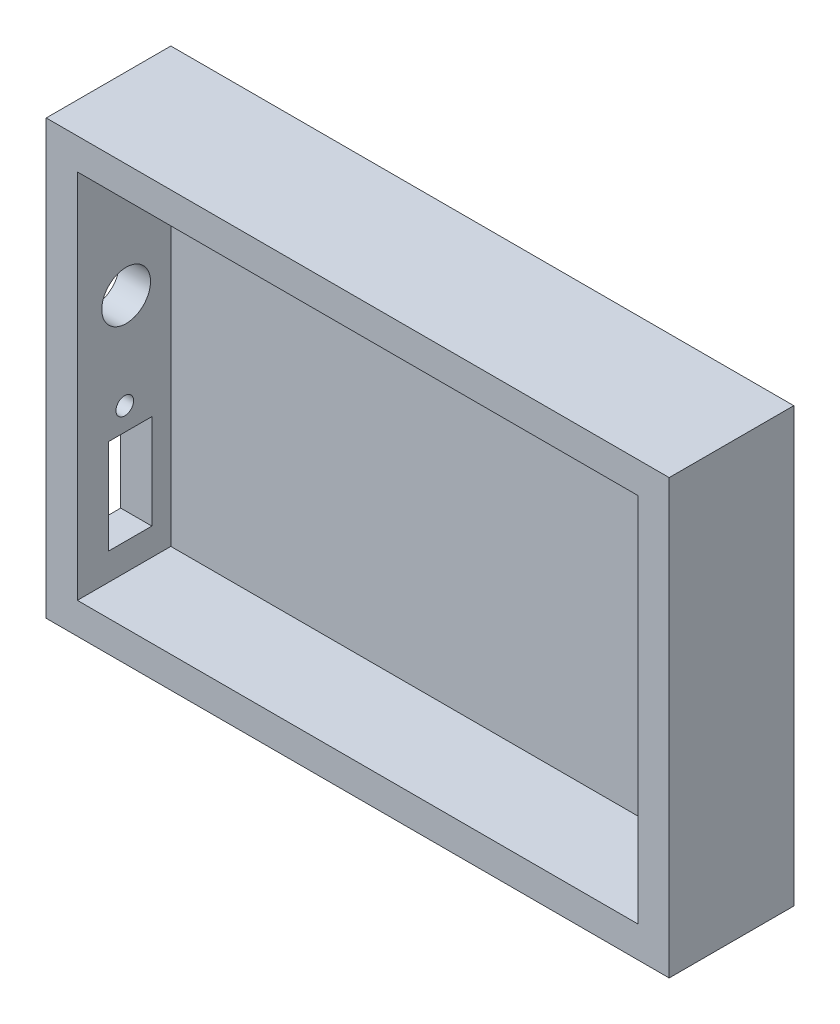
from build123d import *

# Parameters (mm, degrees)
SKETCH1_W           = 230
SKETCH1_H           = 160
BOSS_EXTRUDE1_DEPTH = 46
SHELL1_T            = -11.5
SKETCH2_R           = 3.25
SKETCH2_R_2         = 9
SKETCH2_W           = 16
SKETCH2_H           = 35
CUT_EXTRUDE1_DEPTH  = 11.5


with BuildPart() as part:
    # Sketch1 → Boss-Extrude1 (new body)
    with BuildSketch(Plane.XY):
        Rectangle(SKETCH1_W, SKETCH1_H)
    extrude(amount=BOSS_EXTRUDE1_DEPTH)

    # Shell1
    shell1_openings = [part.faces().sort_by_distance(p)[0] for p in [
        (0, 0, 46),
    ]]
    offset(amount=SHELL1_T, openings=shell1_openings, kind=Kind.INTERSECTION)

    # Sketch2 → Cut-Extrude1 (cut)
    with BuildSketch(Plane.ZY.offset(115)):
        with Locations((28.5, -15)):
            Circle(SKETCH2_R)
        with Locations((28, 20)):
            Circle(SKETCH2_R_2)
        with Locations((26.5, -41)):
            Rectangle(SKETCH2_W, SKETCH2_H)
    extrude(amount=-CUT_EXTRUDE1_DEPTH, mode=Mode.SUBTRACT)


solid = part.part
